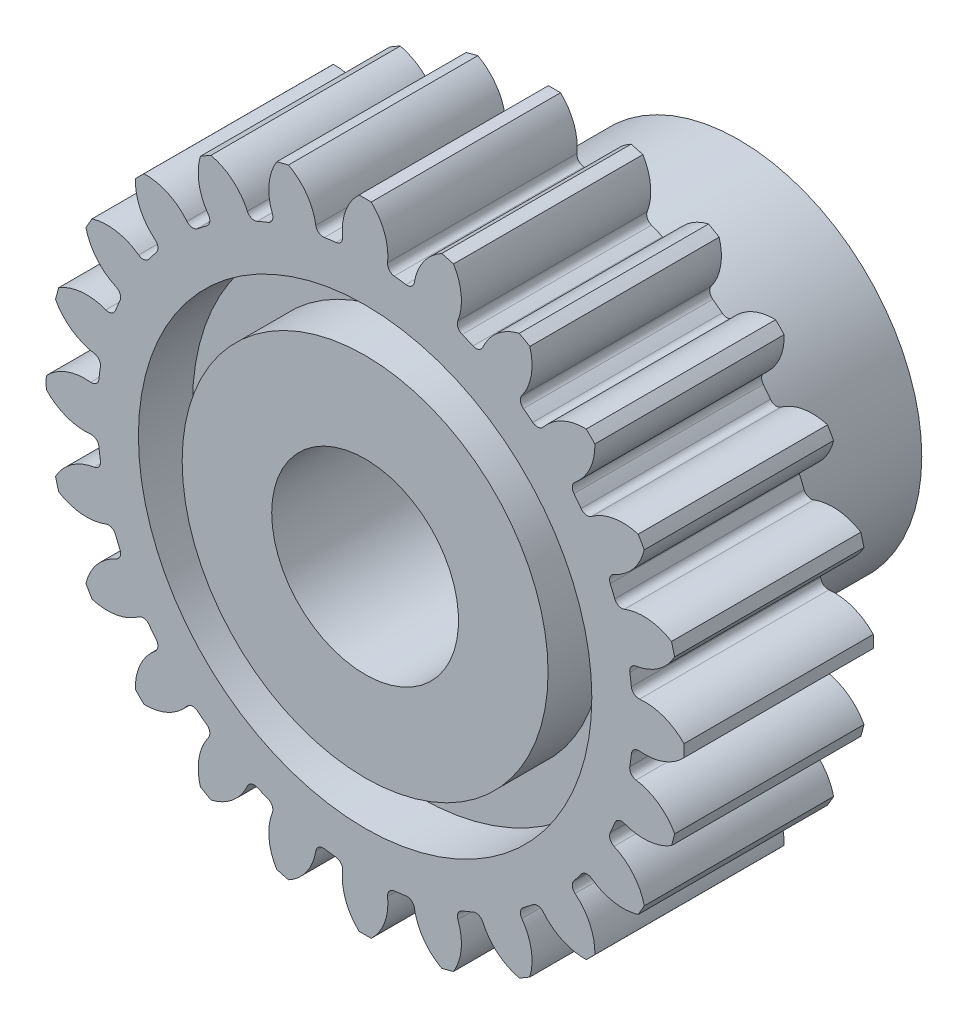
from build123d import *

# Parameters (mm, degrees)
CUT_EXTRUDE1_START = -20.05
CUT_EXTRUDE1_DEPTH = 21.05
CIRPATTERN1_COUNT  = 24


with BuildPart() as part:
    # Sketch3 → Revolve1 (revolve)
    with BuildSketch(Plane(origin=(0, 0, 0), x_dir=(0, 0, -1), z_dir=(1, 0, 0))):
        Polygon((-9.525, 16.256), (0.127, 16.256), (0.127, 11.557), (-2.630714286, 11.557), (-2.630714286, 9.32688), (9.525, 9.32688), (9.525, 4.7625), (-9.525, 4.7625), (-9.525, 9.32688), (-6.767285714, 9.32688), (-6.767285714, 11.557), (-9.525, 11.557), align=None)
    revolve(axis=Axis((0, 0, -9.525), (0, 0, 1)))

    # Sketch4 → Cut-Extrude1 (cut)
    with BuildSketch(Plane.XY.offset(9.525).offset(CUT_EXTRUDE1_START)):
        with BuildLine():
            ThreePointArc((-0.311033322, 16.253024158), (-0.993075864, 15.21927594), (-1.146582013, 13.990352317))
            ThreePointArc((-1.146582013, 13.990352317), (-1.228821857, 13.711265456), (-1.484059766, 13.571599864))
            ThreePointArc((-1.484059766, 13.571599864), (-1.782008839, 13.53570097), (-2.079096861, 13.493261744))
            ThreePointArc((-2.079096861, 13.493261744), (-2.361785865, 13.562107915), (-2.513456449, 13.810399884))
            ThreePointArc((-2.513456449, 13.810399884), (-2.979800841, 14.957718635), (-3.906157074, 15.779717137))
            ThreePointArc((-3.906157074, 15.779717137), (-2.121833781, 16.116927666), (-0.311033322, 16.253024158))
        make_face()
    cut_extrude1 = extrude(amount=CUT_EXTRUDE1_DEPTH, mode=Mode.SUBTRACT)

    # CirPattern1: Cut-Extrude1 ×24 about axis
    cirpattern1_axis = Axis((0, 0, 0), (0, 0, 1))
    for i in range(1, CIRPATTERN1_COUNT):
        add(cut_extrude1.rotate(cirpattern1_axis, i * 360 / CIRPATTERN1_COUNT), mode=Mode.SUBTRACT)


solid = part.part
